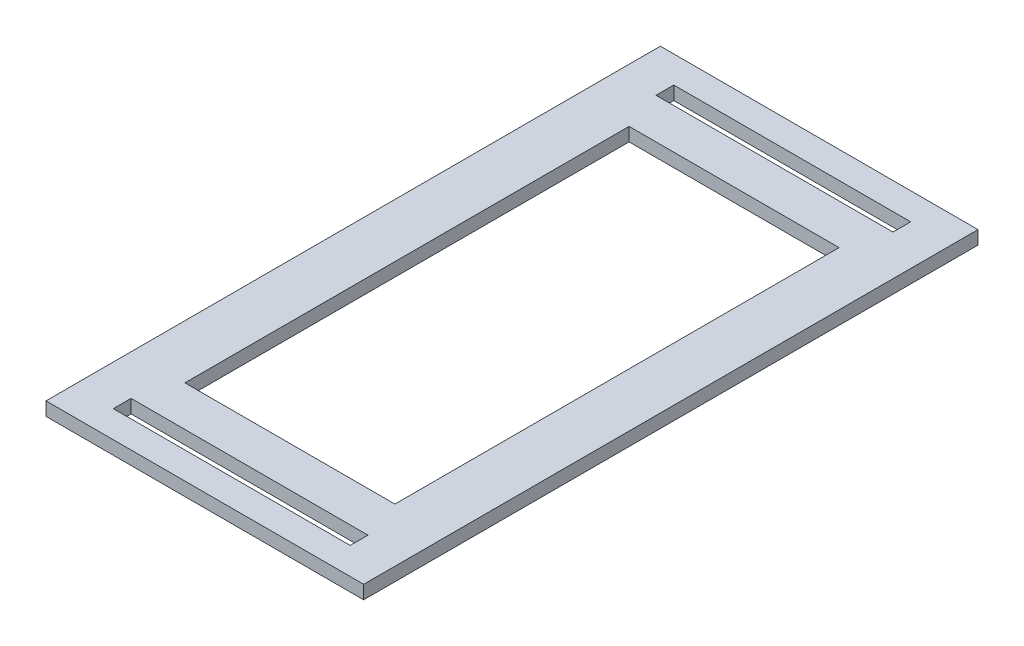
from build123d import *

# Parameters (mm, degrees)
SKETCH1_W           = 74.93
SKETCH1_H           = 144.907
SKETCH1_W_2         = 55.88
SKETCH1_H_2         = 4.191
SKETCH1_W_3         = 49.53
SKETCH1_H_3         = 104.775
BOSS_EXTRUDE1_DEPTH = 3.175


with BuildPart() as part:
    # Sketch1 → Boss-Extrude1 (new body)
    with BuildSketch(Plane(origin=(0, 0, 0), x_dir=(1, 0, 0), z_dir=(0, 1, 0))):
        Rectangle(SKETCH1_W, SKETCH1_H)
        with Locations((0, -64.008)):
            Rectangle(SKETCH1_W_2, SKETCH1_H_2, mode=Mode.SUBTRACT)
        with Locations((0, 64.008)):
            Rectangle(SKETCH1_W_2, SKETCH1_H_2, mode=Mode.SUBTRACT)
        Rectangle(SKETCH1_W_3, SKETCH1_H_3, mode=Mode.SUBTRACT)
    extrude(amount=BOSS_EXTRUDE1_DEPTH)


solid = part.part
